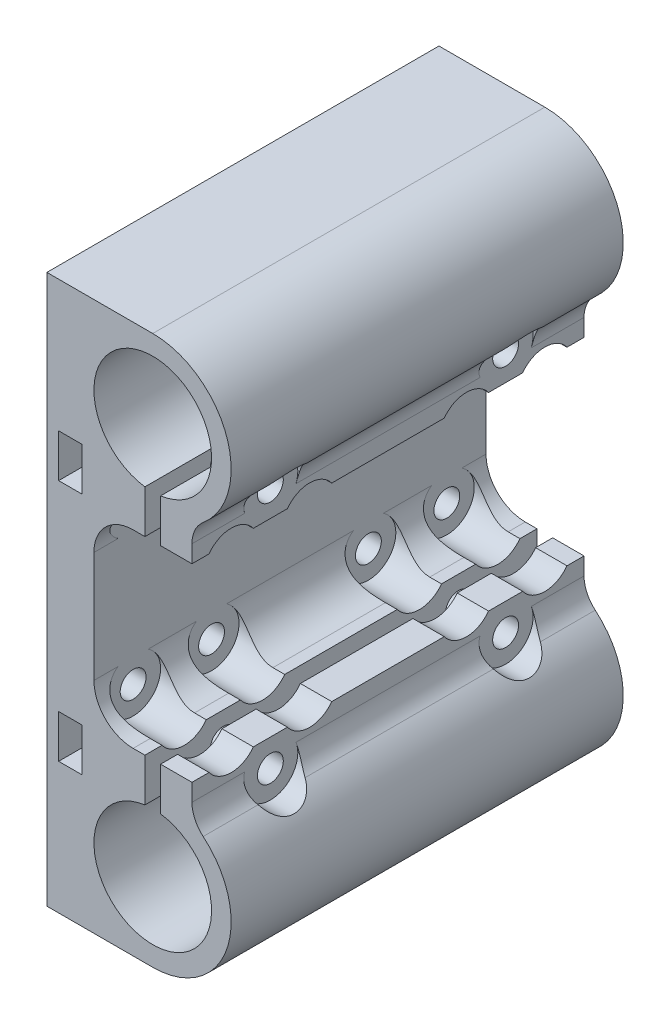
from build123d import *

# Parameters (mm, degrees)
ESBO_O1_W                  = 3
ESBO_O1_H                  = 5.5
RESSALTO_EXTRUS_O1_DEPTH   = 50
ESBO_O6_R                  = 1.65
CORTE_EXTRUS_O3_DEPTH      = 15.5
CORTE_EXTRUS_O3_DEPTH_BACK = 10
ESBO_O7_R                  = 3.5
CORTE_EXTRUS_O4_DEPTH      = 10
ESBO_O9_R                  = 1.65
CORTE_EXTRUS_O6_DEPTH      = 18.5000001
CORTE_EXTRUS_O6_DEPTH_BACK = 7
ESBO_O10_R                 = 3.5
ESBO_O10_R_2               = 1.65
CORTE_EXTRUS_O7_DEPTH      = 18.5000001


with BuildPart() as part:
    # Esboço1 → Ressalto-extrusão1 (new body)
    with BuildSketch(Plane.XY):
        with BuildLine():
            Line((0, 35), (0, -35))
            Line((0, -35), (13.5, -35))
            ThreePointArc((13.5, -35), (22.896770968, -28.420627921), (19.928571429, -17.340139075))
            ThreePointArc((19.928571429, -17.340139075), (18.874692131, -15.966503215), (18.5, -14.276194705))
            Line((18.5, -14.276194705), (18.5, -12.066965626))
            Line((18.5, -12.066965626), (14.5, -12.066965626))
            Line((14.5, -12.066965626), (14.5, -17.566965626))
            ThreePointArc((14.5, -17.566965626), (13.5, -32.5), (12.5, -17.566965626))
            Line((12.5, -17.566965626), (12.5, -12.066965626))
            Line((12.5, -12.066965626), (11, -12.066965626))
            ThreePointArc((11, -12.066965626), (7.464466094, -10.602499532), (6, -7.066965626))
            Line((6, -7.066965626), (6, 7.066965626))
            ThreePointArc((6, 7.066965626), (7.464466094, 10.602499532), (11, 12.066965626))
            Line((11, 12.066965626), (12.5, 12.066965626))
            Line((12.5, 12.066965626), (12.5, 17.566965626))
            ThreePointArc((12.5, 17.566965626), (13.5, 32.5), (14.5, 17.566965626))
            Line((14.5, 17.566965626), (14.5, 12.066965626))
            Line((14.5, 12.066965626), (18.5, 12.066965626))
            Line((18.5, 12.066965626), (18.5, 14.276194705))
            ThreePointArc((18.5, 14.276194705), (18.874692131, 15.966503215), (19.928571429, 17.340139075))
            ThreePointArc((19.928571429, 17.340139075), (22.896770968, 28.420627921), (13.5, 35))
            Line((13.5, 35), (0, 35))
        make_face()
        with Locations((3, 15.5)):
            Rectangle(ESBO_O1_W, ESBO_O1_H, mode=Mode.SUBTRACT)
        with Locations((3, -15.5)):
            Rectangle(ESBO_O1_W, ESBO_O1_H, mode=Mode.SUBTRACT)
    extrude(amount=RESSALTO_EXTRUS_O1_DEPTH)

    # Esboço6 → Corte-extrusão3 (cut, two sides)
    with BuildSketch(Plane.ZY.offset(-14.5)) as corte_extrus_o3_sk:
        with Locations((10, 15.533482813)):
            Circle(ESBO_O6_R)
        with Locations((40, 15.533482813)):
            Circle(ESBO_O6_R)
        with Locations((40, -15.533482813)):
            Circle(ESBO_O6_R)
        with Locations((10, -15.533482813)):
            Circle(ESBO_O6_R)
    extrude(amount=CORTE_EXTRUS_O3_DEPTH, mode=Mode.SUBTRACT)
    extrude(corte_extrus_o3_sk.sketch, amount=-CORTE_EXTRUS_O3_DEPTH_BACK, mode=Mode.SUBTRACT)

    # Esboço7 → Corte-extrusão4 (cut)
    with BuildSketch(Plane(origin=(18.5, 0, 0), x_dir=(0, 0, -1), z_dir=(1, 0, 0))):
        with Locations((-40, 15.533482813)):
            Circle(ESBO_O7_R)
        with Locations((-10, 15.533482813)):
            Circle(ESBO_O7_R)
        with Locations((-10, -15.533482813)):
            Circle(ESBO_O7_R)
        with Locations((-40, -15.533482813)):
            Circle(ESBO_O7_R)
    extrude(amount=CORTE_EXTRUS_O4_DEPTH, mode=Mode.SUBTRACT)

    # Esboço9 → Corte-extrusão6 (cut, two sides)
    with BuildSketch(Plane(origin=(6, 0, 0), x_dir=(0, 0, -1), z_dir=(1, 0, 0))) as corte_extrus_o6_sk:
        with Locations((-45, 10)):
            Circle(ESBO_O9_R)
        with Locations((-35, 10)):
            Circle(ESBO_O9_R)
        with Locations((-15, 10)):
            Circle(ESBO_O9_R)
        with Locations((-5, 10)):
            Circle(ESBO_O9_R)
        with Locations((-5, -10)):
            Circle(ESBO_O9_R)
        with Locations((-15, -10)):
            Circle(ESBO_O9_R)
        with Locations((-35, -10)):
            Circle(ESBO_O9_R)
        with Locations((-45, -10)):
            Circle(ESBO_O9_R)
    extrude(amount=CORTE_EXTRUS_O6_DEPTH, mode=Mode.SUBTRACT)
    extrude(corte_extrus_o6_sk.sketch, amount=-CORTE_EXTRUS_O6_DEPTH_BACK, mode=Mode.SUBTRACT)

    # Esboço10 → Corte-extrusão7 (cut, through all)
    with BuildSketch(Plane(origin=(6, 0, 0), x_dir=(0, 0, -1), z_dir=(1, 0, 0))):
        with Locations((-45, 10)):
            Circle(ESBO_O10_R)
        with Locations((-45, 10)):
            Circle(ESBO_O10_R_2, mode=Mode.SUBTRACT)
        with Locations((-35, 10)):
            Circle(ESBO_O10_R)
        with Locations((-35, 10)):
            Circle(ESBO_O10_R_2, mode=Mode.SUBTRACT)
        with Locations((-15, 10)):
            Circle(ESBO_O10_R)
        with Locations((-15, 10)):
            Circle(ESBO_O10_R_2, mode=Mode.SUBTRACT)
        with Locations((-5, 10)):
            Circle(ESBO_O10_R)
        with Locations((-5, 10)):
            Circle(ESBO_O10_R_2, mode=Mode.SUBTRACT)
        with Locations((-5, -10)):
            Circle(ESBO_O10_R)
        with Locations((-5, -10)):
            Circle(ESBO_O10_R_2, mode=Mode.SUBTRACT)
        with Locations((-15, -10)):
            Circle(ESBO_O10_R)
        with Locations((-15, -10)):
            Circle(ESBO_O10_R_2, mode=Mode.SUBTRACT)
        with Locations((-35, -10)):
            Circle(ESBO_O10_R)
        with Locations((-35, -10)):
            Circle(ESBO_O10_R_2, mode=Mode.SUBTRACT)
        with Locations((-45, -10)):
            Circle(ESBO_O10_R)
        with Locations((-45, -10)):
            Circle(ESBO_O10_R_2, mode=Mode.SUBTRACT)
    extrude(amount=CORTE_EXTRUS_O7_DEPTH, mode=Mode.SUBTRACT)


solid = part.part
